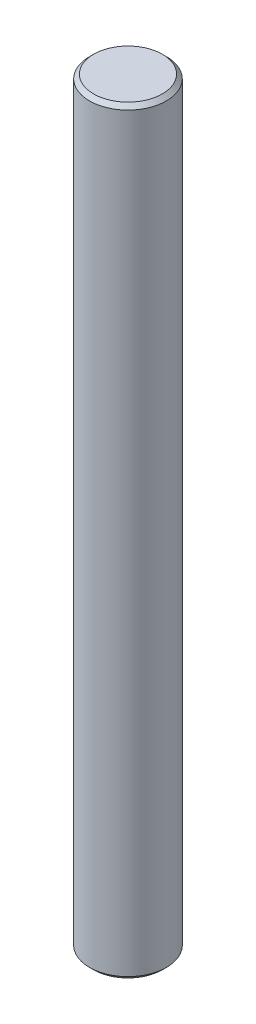
from build123d import *

# Parameters (mm, degrees)
SKETCH2_R           = 4.826
BOSS_EXTRUDE1_DEPTH = 47.625
CHAMFER1_SIZE       = 0.508


with BuildPart() as part:
    # Sketch2 → Boss-Extrude1 (new body, symmetric)
    with BuildSketch(Plane(origin=(0, 0, 0), x_dir=(1, 0, 0), z_dir=(0, 1, 0))):
        Circle(SKETCH2_R)
    extrude(amount=BOSS_EXTRUDE1_DEPTH, both=True)

    # Chamfer1
    chamfer1_edges = [part.edges().sort_by_distance(p)[0] for p in [
        (-4.826, -47.625, 0),
        (-4.826, 47.625, 0),
    ]]
    chamfer(chamfer1_edges, length=CHAMFER1_SIZE)


solid = part.part
